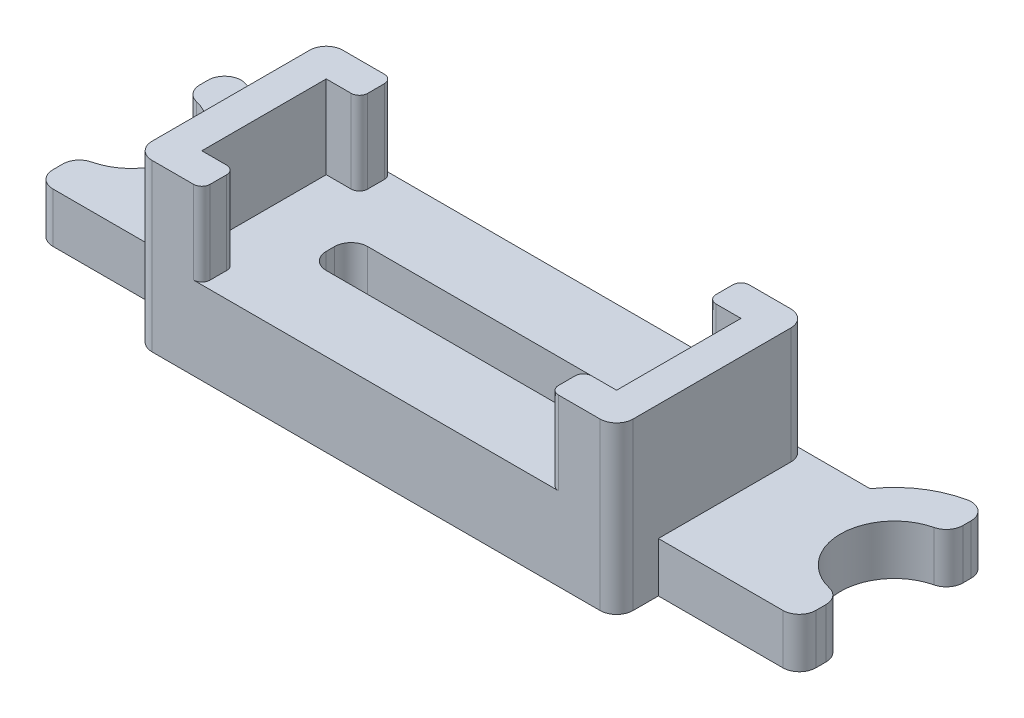
from build123d import *

# Parameters (mm, degrees)
MAIN_BODY_DEPTH            = 3
SKETCH2_W                  = 29
SKETCH2_H                  = 11.5
FAN_OFFSET_DEPTH           = 2
FAN_FRAME_DEPTH            = 5
SKETCH4_W                  = 17
SKETCH4_H                  = 2.5
SPEED_HOLE_DEPTH           = 6
CONTOURING_R               = 1
FIT_CLEARANCE_CONTOURING_R = 0.5


with BuildPart() as part:
    # Sketch1 → Main Body (new body)
    with BuildSketch(Plane(origin=(0, 0, 0), x_dir=(1, 0, 0), z_dir=(0, 1, 0))):
        with BuildLine():
            Line((-23, -3.25), (-23, -5.73))
            Line((-23, -5.73), (-14.5, -5.73))
            Line((-14.5, -5.73), (-14.5, -8.25))
            Line((-14.5, -8.25), (14.5, -8.25))
            Line((14.5, -8.25), (14.5, -5.73))
            Line((14.5, -5.73), (23, -5.73))
            Line((23, -5.73), (23, -3.25))
            ThreePointArc((23, -3.25), (19.75, 0), (23, 3.25))
            Line((23, 3.25), (23, 5.73))
            ThreePointArc((23, 5.73), (20.334441897, 5.072248022), (18.280847534, 3.25))
            Line((18.280847534, 3.25), (-18.280847534, 3.25))
            ThreePointArc((-18.280847534, 3.25), (-20.334441897, 5.072248022), (-23, 5.73))
            Line((-23, 5.73), (-23, 3.25))
            ThreePointArc((-23, 3.25), (-19.75, 0), (-23, -3.25))
        make_face()
    extrude(amount=MAIN_BODY_DEPTH)

    # Sketch2 → Fan Offset (add)
    with BuildSketch(Plane(origin=(0, 3, 0), x_dir=(1, 0, 0), z_dir=(0, 1, 0))):
        with Locations((0, -2.5)):
            Rectangle(SKETCH2_W, SKETCH2_H)
    extrude(amount=FAN_OFFSET_DEPTH)

    # Sketch3 → Fan Frame (add)
    with BuildSketch(Plane(origin=(0, 5, 0), x_dir=(1, 0, 0), z_dir=(0, 1, 0))):
        Polygon((-10.5, 3.25), (-14.5, 3.25), (-14.5, -8.25), (-10.5, -8.25), (-10.5, -6.25), (-12.5, -6.25), (-12.5, 1.25), (-10.5, 1.25), align=None)
        Polygon((12.5, -6.25), (12.5, 1.25), (10.5, 1.25), (10.5, 3.25), (14.5, 3.25), (14.5, -8.25), (10.5, -8.25), (10.5, -6.25), align=None)
    extrude(amount=FAN_FRAME_DEPTH)

    # Sketch4 → Speed Hole (cut, through all)
    with BuildSketch(Plane(origin=(0, 5, 0), x_dir=(1, 0, 0), z_dir=(0, 1, 0))):
        with Locations((0, -2.5)):
            Rectangle(SKETCH4_W, SKETCH4_H)
    extrude(amount=-SPEED_HOLE_DEPTH, mode=Mode.SUBTRACT)

    # Contouring
    contouring_edges = [part.edges().sort_by_distance(p)[0] for p in [
        (-14.5, 6.5, -3.25),
        (14.5, 6.5, -3.25),
        (14.5, 5, 8.25),
        (-14.5, 5, 8.25),
        (23, 1.5, 5.73),
        (23, 1.5, 3.25),
        (23, 1.5, -3.25),
        (23, 1.5, -5.73),
        (-23, 1.5, 5.73),
        (-23, 1.5, 3.25),
        (-23, 1.5, -3.25),
        (-23, 1.5, -5.73),
        (-8.5, 2.5, 1.25),
        (-8.5, 2.5, 3.75),
        (8.5, 2.5, 3.75),
        (8.5, 2.5, 1.25),
    ]]
    fillet(contouring_edges, radius=CONTOURING_R)

    # Fit Clearance - Contouring
    fit_clearance_contouring_edges = [part.edges().sort_by_distance(p)[0] for p in [
        (10.5, 7.5, -3.25),
        (-10.5, 7.5, -3.25),
        (-10.5, 7.5, 8.25),
        (-10.5, 7.5, 6.25),
        (10.5, 7.5, 8.25),
        (10.5, 7.5, 6.25),
        (10.5, 7.5, -1.25),
        (-10.5, 7.5, -1.25),
    ]]
    fillet(fit_clearance_contouring_edges, radius=FIT_CLEARANCE_CONTOURING_R)


solid = part.part
